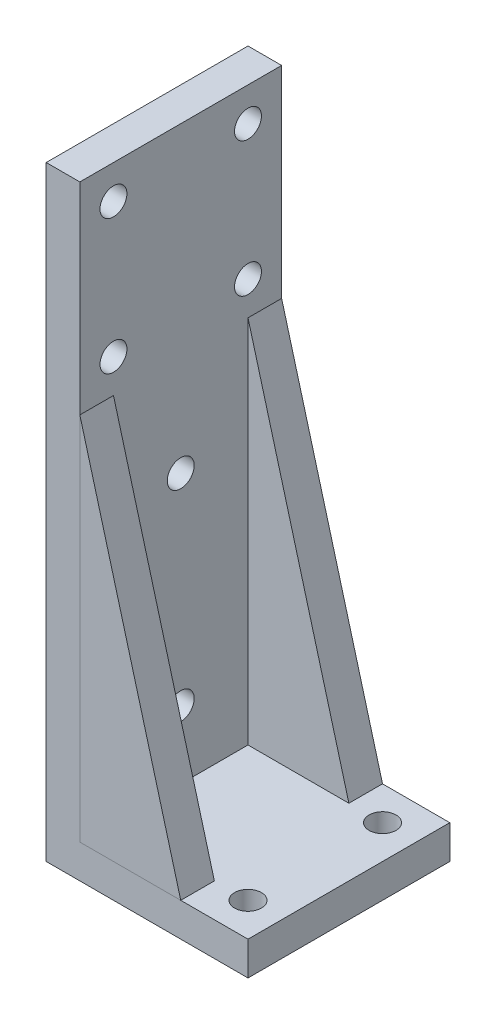
from build123d import *

# Parameters (mm, degrees)
SKETCH1_W           = 30
SKETCH1_H           = 30
BOSS_EXTRUDE1_DEPTH = 5
SKETCH2_W           = 5
SKETCH2_H           = 30
BOSS_EXTRUDE2_DEPTH = 85
BOSS_EXTRUDE3_DEPTH = 5
BOSS_EXTRUDE4_DEPTH = 5
SKETCH10_R          = 2
CUT_EXTRUDE1_DEPTH  = 5
SKETCH11_R          = 2
CUT_EXTRUDE2_DEPTH  = 5
SKETCH12_R          = 2
CUT_EXTRUDE3_DEPTH  = 5


with BuildPart() as part:
    # Sketch1 → Boss-Extrude1 (new body)
    with BuildSketch(Plane(origin=(0, 0, 0), x_dir=(1, 0, 0), z_dir=(0, 1, 0))):
        Rectangle(SKETCH1_W, SKETCH1_H)
    extrude(amount=BOSS_EXTRUDE1_DEPTH)

    # Sketch2 → Boss-Extrude2 (add)
    with BuildSketch(Plane(origin=(0, 5, 0), x_dir=(1, 0, 0), z_dir=(0, 1, 0))):
        with Locations((-12.5, 0)):
            Rectangle(SKETCH2_W, SKETCH2_H)
    extrude(amount=BOSS_EXTRUDE2_DEPTH)

    # Sketch5 → Boss-Extrude4 (add)
    with BuildSketch(Plane.XY.offset(-15)):
        Polygon((-10, 5), (-10, 60), (5, 5), align=None)
    extrude(amount=BOSS_EXTRUDE4_DEPTH)

    # Sketch10 → Cut-Extrude1 (cut)
    with BuildSketch(Plane(origin=(-10, 0, 0), x_dir=(0, 0, -1), z_dir=(1, 0, 0))):
        with Locations((-10, 85)):
            Circle(SKETCH10_R)
        with Locations((10, 85)):
            Circle(SKETCH10_R)
        with Locations((0, 15)):
            Circle(SKETCH10_R)
        with Locations((0, 45)):
            Circle(SKETCH10_R)
    extrude(amount=-CUT_EXTRUDE1_DEPTH, mode=Mode.SUBTRACT)

    # Sketch11 → Cut-Extrude2 (cut)
    with BuildSketch(Plane(origin=(0, 5, 0), x_dir=(1, 0, 0), z_dir=(0, 1, 0))):
        with Locations((10, 10)):
            Circle(SKETCH11_R)
        with Locations((10, -10)):
            Circle(SKETCH11_R)
    extrude(amount=-CUT_EXTRUDE2_DEPTH, mode=Mode.SUBTRACT)

    # Sketch12 → Cut-Extrude3 (cut)
    with BuildSketch(Plane(origin=(-10, 0, 0), x_dir=(0, 0, -1), z_dir=(1, 0, 0))):
        with Locations((-10, 65)):
            Circle(SKETCH12_R)
        with Locations((10, 65)):
            Circle(SKETCH12_R)
    extrude(amount=-CUT_EXTRUDE3_DEPTH, mode=Mode.SUBTRACT)


with BuildPart() as body_2:
    # Sketch3 → Boss-Extrude3 (new body)
    with BuildSketch(Plane.XY.offset(15)):
        Polygon((-10, 5), (-10, 60), (5, 5), align=None)
    extrude(amount=-BOSS_EXTRUDE3_DEPTH)


solid = Compound([part.part, body_2.part])
